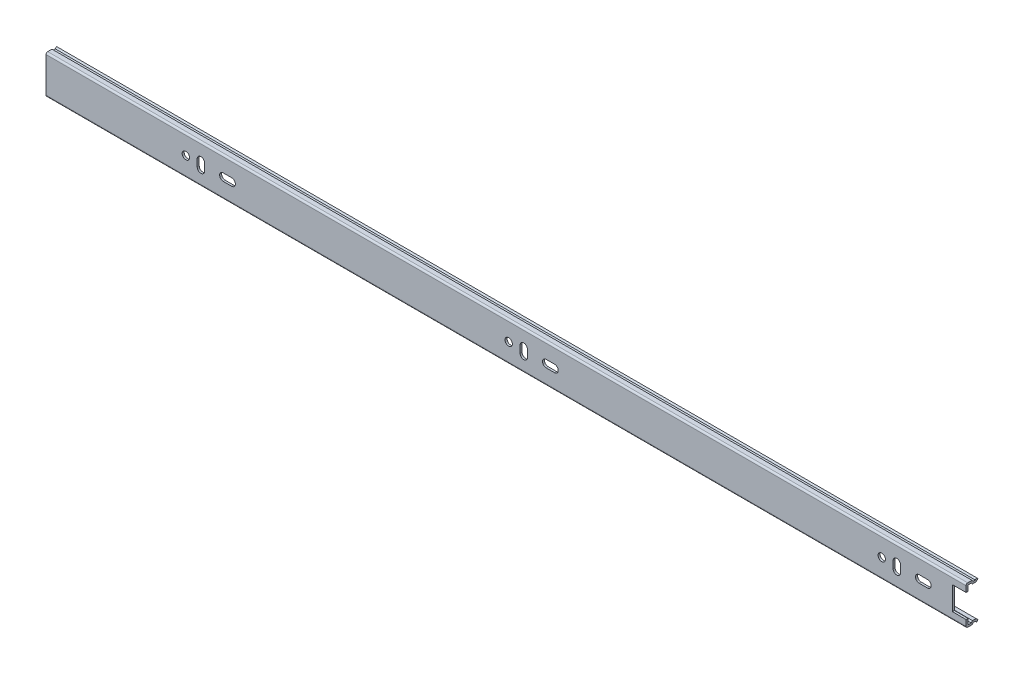
from build123d import *

# Parameters (mm, degrees)
EXTRUDE_3_DEPTH     = 550
SKETCH_2_R          = 2.2
SKETCH_2_W          = 8.2
SKETCH_2_H          = 14
CUT_EXTRUDE_1_DEPTH = 8.148528137


with BuildPart() as part:
    # Эскиз1 → Вытянуть-Тонкостенный3 (new body)
    with BuildSketch(Plane(origin=(0, 0, 0), x_dir=(0, 0, -1), z_dir=(1, 0, 0))):
        with BuildLine():
            Line((6.3, 11.5), (5.501920783, 10.701920783))
            Line((5.501920783, 10.701920783), (4.371381229, 10.701920783))
            Line((4.371381229, 10.701920783), (3.573302011, 11.5))
            Line((3.573302011, 11.5), (1, 11.5))
            ThreePointArc((1, 11.5), (0.292893219, 11.207106781), (0, 10.5))
            Line((0, 10.5), (0, -10.5))
            ThreePointArc((0, -10.5), (0.292893219, -11.207106781), (1, -11.5))
            Line((1, -11.5), (3.573302011, -11.5))
            Line((3.573302011, -11.5), (4.371381229, -10.701920783))
            Line((4.371381229, -10.701920783), (5.501920783, -10.701920783))
            Line((5.501920783, -10.701920783), (6.3, -11.5))
            Line((6.3, -11.5), (7.148528137, -10.651471863))
            Line((7.148528137, -10.651471863), (5.998977057, -9.501920783))
            Line((5.998977057, -9.501920783), (3.874324954, -9.501920783))
            Line((3.874324954, -9.501920783), (3.076245737, -10.3))
            Line((3.076245737, -10.3), (1.2, -10.3))
            Line((1.2, -10.3), (1.2, 10.3))
            Line((1.2, 10.3), (3.076245737, 10.3))
            Line((3.076245737, 10.3), (3.874324954, 9.501920783))
            Line((3.874324954, 9.501920783), (5.998977057, 9.501920783))
            Line((5.998977057, 9.501920783), (7.148528137, 10.651471863))
            Line((7.148528137, 10.651471863), (6.3, 11.5))
        make_face()
    extrude(amount=EXTRUDE_3_DEPTH)

    # Эскиз2 → Вырез-Вытянуть1 (cut, through all)
    with BuildSketch(Plane.XY):
        with Locations((499.6, 0)):
            Circle(SKETCH_2_R)
        with Locations((276.6, 0)):
            Circle(SKETCH_2_R)
        with Locations((83.6, 0)):
            Circle(SKETCH_2_R)
        with Locations((545.9, 0)):
            Rectangle(SKETCH_2_W, SKETCH_2_H)
        with BuildLine():
            Line((522, 2.2), (527, 2.2))
            ThreePointArc((527, 2.2), (529.2, 0), (527, -2.2))
            Line((527, -2.2), (522, -2.2))
            ThreePointArc((522, -2.2), (519.8, 0), (522, 2.2))
        make_face()
        with BuildLine():
            Line((506.4, 1.779598361), (506.4, -2.5))
            ThreePointArc((506.4, -2.5), (508.6, -4.7), (510.8, -2.5))
            Line((510.8, -2.5), (510.8, 1.779598361))
            ThreePointArc((510.8, 1.779598361), (508.6, 3.979598361), (506.4, 1.779598361))
        make_face()
        with BuildLine():
            Line((283.4, 1.779598361), (283.4, -2.5))
            ThreePointArc((283.4, -2.5), (285.6, -4.7), (287.8, -2.5))
            Line((287.8, -2.5), (287.8, 1.779598361))
            ThreePointArc((287.8, 1.779598361), (285.6, 3.979598361), (283.4, 1.779598361))
        make_face()
        with BuildLine():
            Line((299, -2.2), (304, -2.2))
            ThreePointArc((304, -2.2), (306.2, 0), (304, 2.2))
            Line((304, 2.2), (299, 2.2))
            ThreePointArc((299, 2.2), (296.8, 0), (299, -2.2))
        make_face()
        with BuildLine():
            Line((94.8, -2.5), (94.8, 1.779598361))
            ThreePointArc((94.8, 1.779598361), (92.6, 3.979598361), (90.4, 1.779598361))
            Line((90.4, 1.779598361), (90.4, -2.5))
            ThreePointArc((90.4, -2.5), (92.6, -4.7), (94.8, -2.5))
        make_face()
        with BuildLine():
            Line((106, 2.2), (111, 2.2))
            ThreePointArc((111, 2.2), (113.2, 0), (111, -2.2))
            Line((111, -2.2), (106, -2.2))
            ThreePointArc((106, -2.2), (103.8, 0), (106, 2.2))
        make_face()
    extrude(amount=-CUT_EXTRUDE_1_DEPTH, mode=Mode.SUBTRACT)


solid = part.part
